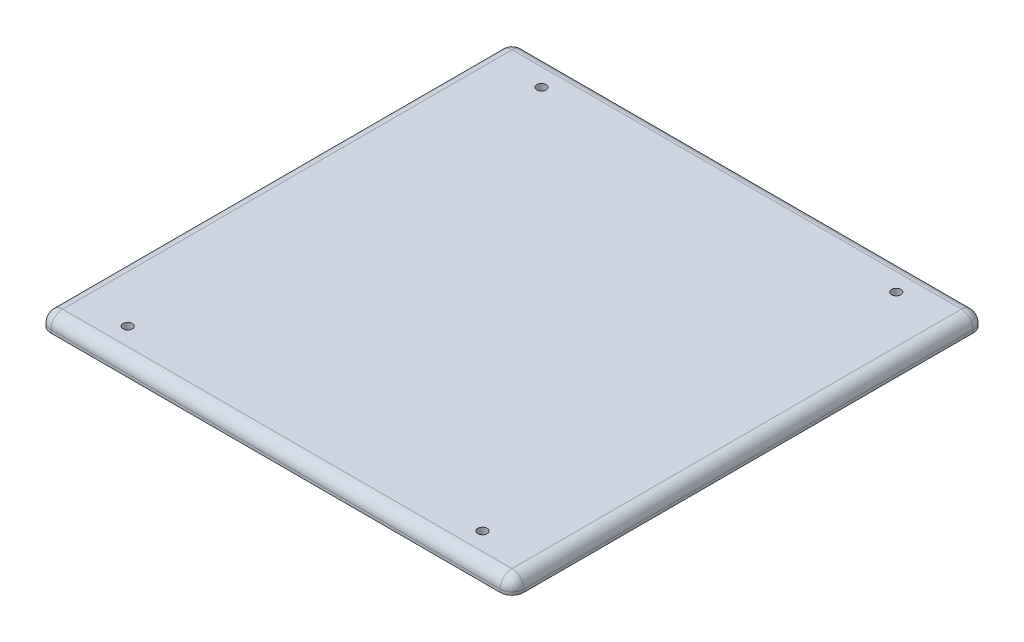
from build123d import *

# Parameters (mm, degrees)
SKETCH1_W           = 101.6
SKETCH1_H           = 101.6
BOSS_EXTRUDE1_DEPTH = 3.175
SKETCH2_R           = 0.99949
CUT_EXTRUDE1_DEPTH  = 3.175
CHAMFER1_SIZE       = 1.27
FILLET1_R           = 2.54


with BuildPart() as part:
    # Sketch1 → Boss-Extrude1 (new body)
    with BuildSketch(Plane(origin=(0, 0, 0), x_dir=(1, 0, 0), z_dir=(0, 1, 0))):
        Rectangle(SKETCH1_W, SKETCH1_H)
    extrude(amount=BOSS_EXTRUDE1_DEPTH)

    # Sketch2 → Cut-Extrude1 (cut)
    with BuildSketch(Plane(origin=(0, 3.175, 0), x_dir=(1, 0, 0), z_dir=(0, 1, 0))):
        with Locations((-38.1, -44.45)):
            Circle(SKETCH2_R)
        with Locations((38.1, -44.45)):
            Circle(SKETCH2_R)
        with Locations((38.1, 44.45)):
            Circle(SKETCH2_R)
        with Locations((-38.1, 44.45)):
            Circle(SKETCH2_R)
    extrude(amount=-CUT_EXTRUDE1_DEPTH, mode=Mode.SUBTRACT)

    # Chamfer1
    chamfer1_edges = [part.edges().sort_by_distance(p)[0] for p in [
        (-39.09949, 0, -44.45),
        (37.10051, 0, -44.45),
        (37.10051, 0, 44.45),
        (-39.09949, 0, 44.45),
    ]]
    chamfer(chamfer1_edges, length=CHAMFER1_SIZE)

    # Fillet1
    fillet1_edges = [part.edges().sort_by_distance(p)[0] for p in [
        (50.8, 3.175, 0),
        (0, 3.175, -50.8),
        (-50.8, 3.175, 0),
        (-50.8, 1.5875, -50.8),
        (50.8, 1.5875, -50.8),
        (50.8, 1.5875, 50.8),
        (-50.8, 1.5875, 50.8),
        (0, 3.175, 50.8),
    ]]
    fillet(fillet1_edges, radius=FILLET1_R)


solid = part.part
